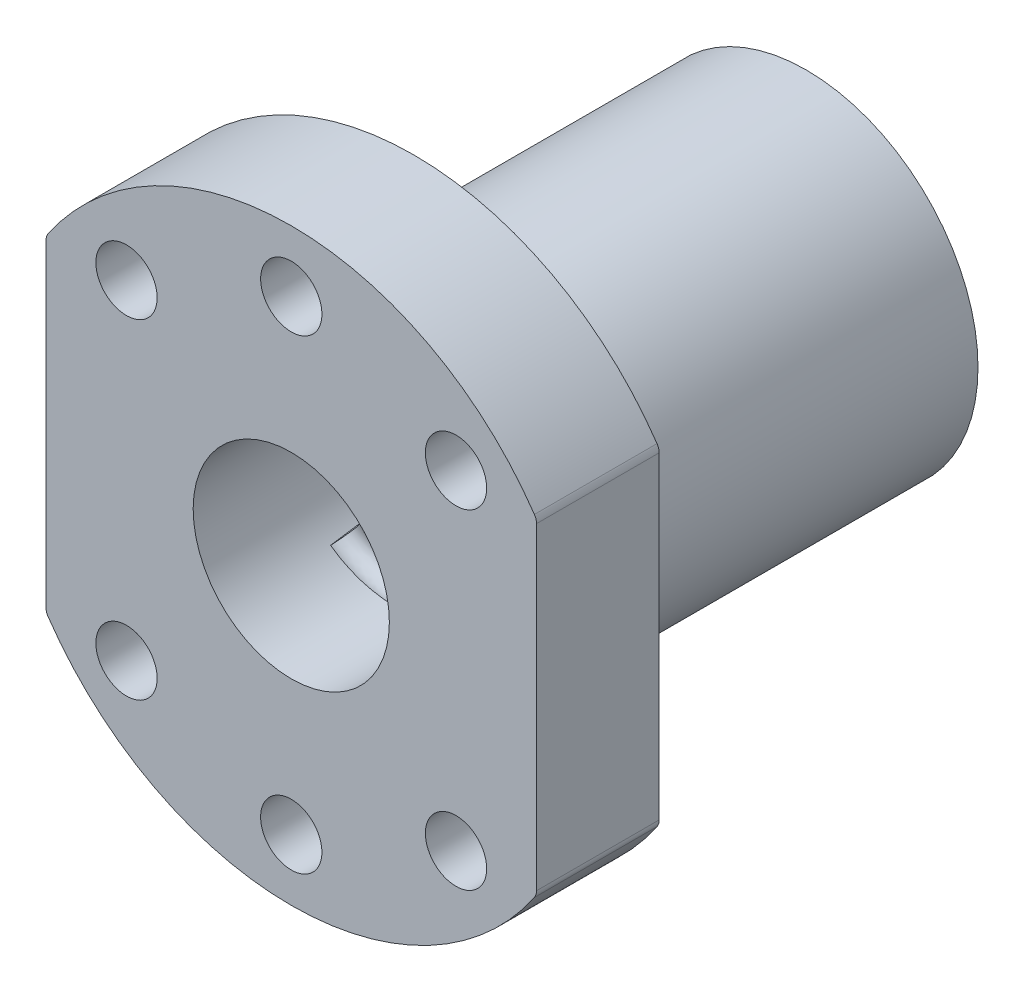
from build123d import *

# Parameters (mm, degrees)
SKETCH1_R           = 8
SKETCH1_R_2         = 2.5
BOSS_EXTRUDE1_DEPTH = 10
SKETCH2_R           = 14
SKETCH2_R_2         = 8
BOSS_EXTRUDE2_DEPTH = 32
SWEEP1_PITCH        = 5
SWEEP1_HEIGHT       = 25
SWEEP1_RADIUS       = 8
SWEEP1_START_ANGLE  = -45
SKETCH5_R           = 1.25
FILLET1_R           = 1


with BuildPart() as part:
    # Sketch1 → Boss-Extrude1 (new body)
    with BuildSketch(Plane.XY):
        with BuildLine():
            Line((-20, 13.266499161), (-20, 0))
            Line((-20, 0), (-20, -13.266499161))
            ThreePointArc((-20, -13.266499161), (0, -24), (20, -13.266499161))
            Line((20, -13.266499161), (20, 0))
            Line((20, 0), (20, 13.266499161))
            ThreePointArc((20, 13.266499161), (0, 24), (-20, 13.266499161))
        make_face()
        Circle(SKETCH1_R, mode=Mode.SUBTRACT)
        with Locations((-13.435028843, -13.435028843)):
            Circle(SKETCH1_R_2, mode=Mode.SUBTRACT)
        with Locations((0, -19)):
            Circle(SKETCH1_R_2, mode=Mode.SUBTRACT)
        with Locations((13.435028843, -13.435028843)):
            Circle(SKETCH1_R_2, mode=Mode.SUBTRACT)
        with Locations(Location((13.435028843, 13.435028843, 0), (0, 0, 180))):
            Circle(SKETCH1_R_2, mode=Mode.SUBTRACT)
        with Locations(Location((0, 19, 0), (0, 0, 180))):
            Circle(SKETCH1_R_2, mode=Mode.SUBTRACT)
        with Locations(Location((-13.435028843, 13.435028843, 0), (0, 0, 180))):
            Circle(SKETCH1_R_2, mode=Mode.SUBTRACT)
    extrude(amount=-BOSS_EXTRUDE1_DEPTH)

    # Sketch2 → Boss-Extrude2 (add)
    with BuildSketch(Plane(origin=(0, 0, -10), x_dir=(-1, 0, 0), z_dir=(0, 0, -1))):
        with Locations(Location((0, 0, 0), (0, 0, 180))):
            Circle(SKETCH2_R)
        with Locations(Location((0, 0, 0), (0, 0, 180))):
            Circle(SKETCH2_R_2, mode=Mode.SUBTRACT)
    extrude(amount=BOSS_EXTRUDE2_DEPTH)

    # Sweep1: sweep along a helix
    with BuildLine() as sweep1_path:
        add(Helix(SWEEP1_PITCH, SWEEP1_HEIGHT, SWEEP1_RADIUS, center=(0, 0, -10), direction=(0, 0, -1), lefthand=True, mode=Mode.PRIVATE).rotate(Axis((0, 0, -10), (0, 0, -1)), SWEEP1_START_ANGLE))
    # Sketch5 → Sweep1 (sweep)
    with BuildSketch(Plane(origin=(-5.656854249, -5.656854249, -10), x_dir=(-0.06999179251368044, 0.06999179251367922, -0.995089090464489), z_dir=(0.7036342437522002, -0.703634243752188, -0.09898334222764968))):
        with Locations((-0.01566852, -0.294802567)):
            Circle(SKETCH5_R)
    sweep(path=sweep1_path.line, is_frenet=True)

    # Fillet1
    fillet1_edges = [part.edges().sort_by_distance(p)[0] for p in [
        (20, 13.266499161, -5),
        (20, -13.266499161, -5),
        (-20, -13.266499161, -5),
        (-20, 13.266499161, -5),
    ]]
    fillet(fillet1_edges, radius=FILLET1_R)


solid = part.part
